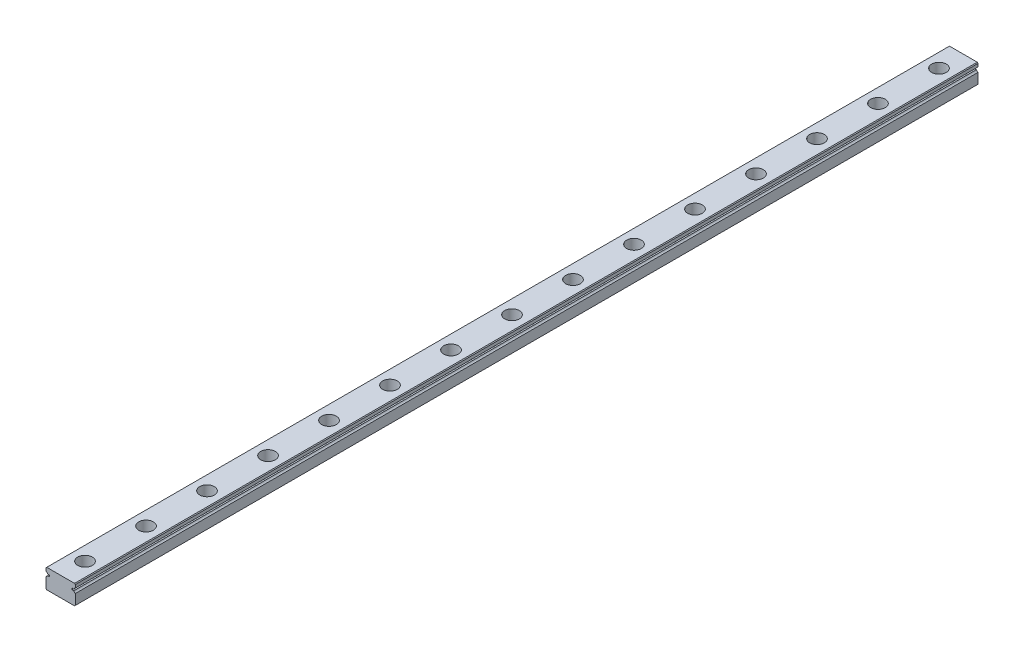
from build123d import *

# Parameters (mm, degrees)
EXTRUDE_1_DEPTH        = 370
SKETCH_2_R             = 3
SKETCH_2_R_2           = 1.75
CUT_EXTRUDE_1_DEPTH    = 4.5
SKETCH_2_2_R           = 1.75
CUT_EXTRUDE_2_DEPTH    = 371.135110466
PATTERN_LINEAR_1_COUNT = 16
PATTERN_LINEAR_1_PITCH = 25


with BuildPart() as part:
    # Эскиз1 → Бобышка-Вытянуть1 (new body)
    with BuildSketch(Plane.XY):
        with BuildLine():
            Line((-6, 3.7), (-5.7, 4))
            Line((-5.7, 4), (5.7, 4))
            Line((5.7, 4), (6, 3.7))
            Line((6, 3.7), (6, 2.451013544))
            ThreePointArc((6, 2.451013544), (5.597935912, 2.202976267), (5.354599002, 1.798050138))
            Line((5.354599002, 1.798050138), (4.643514056, 1.798050138))
            Line((4.643514056, 1.798050138), (4.643514056, 1.201949862))
            Line((4.643514056, 1.201949862), (5.354599002, 1.201949862))
            ThreePointArc((5.354599002, 1.201949862), (5.597935912, 0.797023733), (6, 0.548986456))
            Line((6, 0.548986456), (6, -3.7))
            Line((6, -3.7), (5.7, -4))
            Line((5.7, -4), (-5.7, -4))
            Line((-5.7, -4), (-6, -3.7))
            Line((-6, -3.7), (-6, 0.548986456))
            ThreePointArc((-6, 0.548986456), (-5.597935912, 0.797023733), (-5.354599002, 1.201949862))
            Line((-5.354599002, 1.201949862), (-4.643514056, 1.201949862))
            Line((-4.643514056, 1.201949862), (-4.643514056, 1.798050138))
            Line((-4.643514056, 1.798050138), (-5.354599002, 1.798050138))
            ThreePointArc((-5.354599002, 1.798050138), (-5.597935912, 2.202976267), (-6, 2.451013544))
            Line((-6, 2.451013544), (-6, 3.7))
        make_face()
    extrude(amount=EXTRUDE_1_DEPTH)

    # Эскиз2 → Вырез-Вытянуть1 (cut)
    with BuildSketch(Plane(origin=(0, 4, 0), x_dir=(1, 0, 0), z_dir=(0, 1, 0))):
        with Locations((0, -10)):
            Circle(SKETCH_2_R)
        with Locations((0, -10)):
            Circle(SKETCH_2_R_2, mode=Mode.SUBTRACT)
    cut_extrude_1 = extrude(amount=-CUT_EXTRUDE_1_DEPTH, mode=Mode.SUBTRACT)

    # Эскиз2<2> → Вырез-Вытянуть2 (cut, through all)
    with BuildSketch(Plane(origin=(0, 4, 0), x_dir=(1, 0, 0), z_dir=(0, 1, 0))):
        with Locations((0, -10)):
            Circle(SKETCH_2_2_R)
    cut_extrude_2 = extrude(amount=-CUT_EXTRUDE_2_DEPTH, mode=Mode.SUBTRACT)

    # Линейный массив1: Вырез-Вытянуть1, Вырез-Вытянуть2 ×16
    with Locations(*[(0, 0, i * PATTERN_LINEAR_1_PITCH) for i in range(1, PATTERN_LINEAR_1_COUNT)]):
        add(cut_extrude_1, mode=Mode.SUBTRACT)
        add(cut_extrude_2, mode=Mode.SUBTRACT)


solid = part.part
